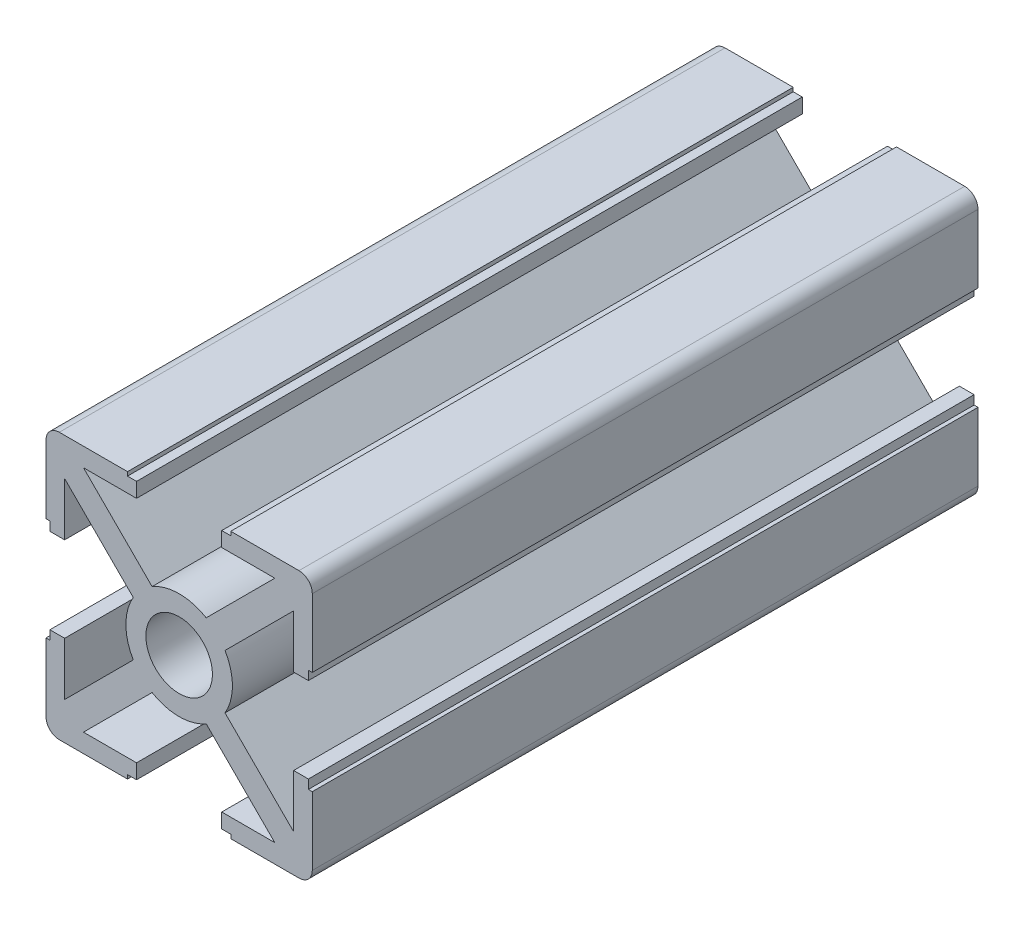
from build123d import *

# Parameters (mm, degrees)
SKETCH1_R               = 2.5
BOSS_EXTRUDE1_DEPTH     = 50
SKETCH2_R               = 2
CUT_EXTRUDE1_DEPTH      = 1
CUT_EXTRUDE1_DEPTH_BACK = 21


with BuildPart() as part:
    # Sketch1 → Boss-Extrude1 (new body)
    with BuildSketch(Plane.XY):
        with BuildLine():
            Line((-9.707106781, -3.2), (-8.6, -3.2))
            Line((-8.6, -3.2), (-8.6, -7.185786438))
            Line((-8.6, -7.185786438), (-3.445719569, -2.031506006))
            ThreePointArc((-3.445719569, -2.031506006), (-4, 0), (-3.445719569, 2.031506006))
            Line((-3.445719569, 2.031506006), (-8.6, 7.185786438))
            Line((-8.6, 7.185786438), (-8.6, 3.2))
            Line((-8.6, 3.2), (-9.707106781, 3.2))
            Line((-9.707106781, 3.2), (-9.707106781, 3.877544562))
            Line((-9.707106781, 3.877544562), (-10, 3.877544562))
            Line((-10, 3.877544562), (-10, 9))
            ThreePointArc((-10, 9), (-9.707106781, 9.707106781), (-9, 10))
            Line((-9, 10), (-3.877544562, 10))
            Line((-3.877544562, 10), (-3.877544562, 9.707106781))
            Line((-3.877544562, 9.707106781), (-3.2, 9.707106781))
            Line((-3.2, 9.707106781), (-3.2, 8.6))
            Line((-3.2, 8.6), (-7.185786438, 8.6))
            Line((-7.185786438, 8.6), (-2.031506006, 3.445719569))
            ThreePointArc((-2.031506006, 3.445719569), (0, 4), (2.031506006, 3.445719569))
            Line((2.031506006, 3.445719569), (7.185786438, 8.6))
            Line((7.185786438, 8.6), (3.2, 8.6))
            Line((3.2, 8.6), (3.2, 9.707106781))
            Line((3.2, 9.707106781), (3.877544562, 9.707106781))
            Line((3.877544562, 9.707106781), (3.877544562, 10))
            Line((3.877544562, 10), (9, 10))
            ThreePointArc((9, 10), (9.707106781, 9.707106781), (10, 9))
            Line((10, 9), (10, 3.877544562))
            Line((10, 3.877544562), (9.707106781, 3.877544562))
            Line((9.707106781, 3.877544562), (9.707106781, 3.2))
            Line((9.707106781, 3.2), (8.6, 3.2))
            Line((8.6, 3.2), (8.6, 7.185786438))
            Line((8.6, 7.185786438), (3.445719569, 2.031506006))
            ThreePointArc((3.445719569, 2.031506006), (4, 0), (3.445719569, -2.031506006))
            Line((3.445719569, -2.031506006), (8.6, -7.185786438))
            Line((8.6, -7.185786438), (8.6, -3.2))
            Line((8.6, -3.2), (9.707106781, -3.2))
            Line((9.707106781, -3.2), (9.707106781, -3.877544562))
            Line((9.707106781, -3.877544562), (10, -3.877544562))
            Line((10, -3.877544562), (10, -9))
            ThreePointArc((10, -9), (9.707106781, -9.707106781), (9, -10))
            Line((9, -10), (3.877544562, -10))
            Line((3.877544562, -10), (3.877544562, -9.707106781))
            Line((3.877544562, -9.707106781), (3.2, -9.707106781))
            Line((3.2, -9.707106781), (3.2, -8.6))
            Line((3.2, -8.6), (7.185786438, -8.6))
            Line((7.185786438, -8.6), (2.031506006, -3.445719569))
            ThreePointArc((2.031506006, -3.445719569), (0, -4), (-2.031506006, -3.445719569))
            Line((-2.031506006, -3.445719569), (-7.185786438, -8.6))
            Line((-7.185786438, -8.6), (-3.2, -8.6))
            Line((-3.2, -8.6), (-3.2, -9.707106781))
            Line((-3.2, -9.707106781), (-3.877544562, -9.707106781))
            Line((-3.877544562, -9.707106781), (-3.877544562, -10))
            Line((-3.877544562, -10), (-9, -10))
            ThreePointArc((-9, -10), (-9.707106781, -9.707106781), (-10, -9))
            Line((-10, -9), (-10, -3.877544562))
            Line((-10, -3.877544562), (-9.707106781, -3.877544562))
            Line((-9.707106781, -3.877544562), (-9.707106781, -3.2))
        make_face()
        Circle(SKETCH1_R, mode=Mode.SUBTRACT)
    extrude(amount=BOSS_EXTRUDE1_DEPTH)

    # Sketch2 → Cut-Extrude1 (cut, two sides)
    with BuildSketch(Plane(origin=(0, 10, 0), x_dir=(1, 0, 0), z_dir=(0, 1, 0))) as cut_extrude1_sk:
        with Locations((0, -42)):
            Circle(SKETCH2_R)
    extrude(amount=CUT_EXTRUDE1_DEPTH, mode=Mode.SUBTRACT)
    extrude(cut_extrude1_sk.sketch, amount=-CUT_EXTRUDE1_DEPTH_BACK, mode=Mode.SUBTRACT)


solid = part.part
